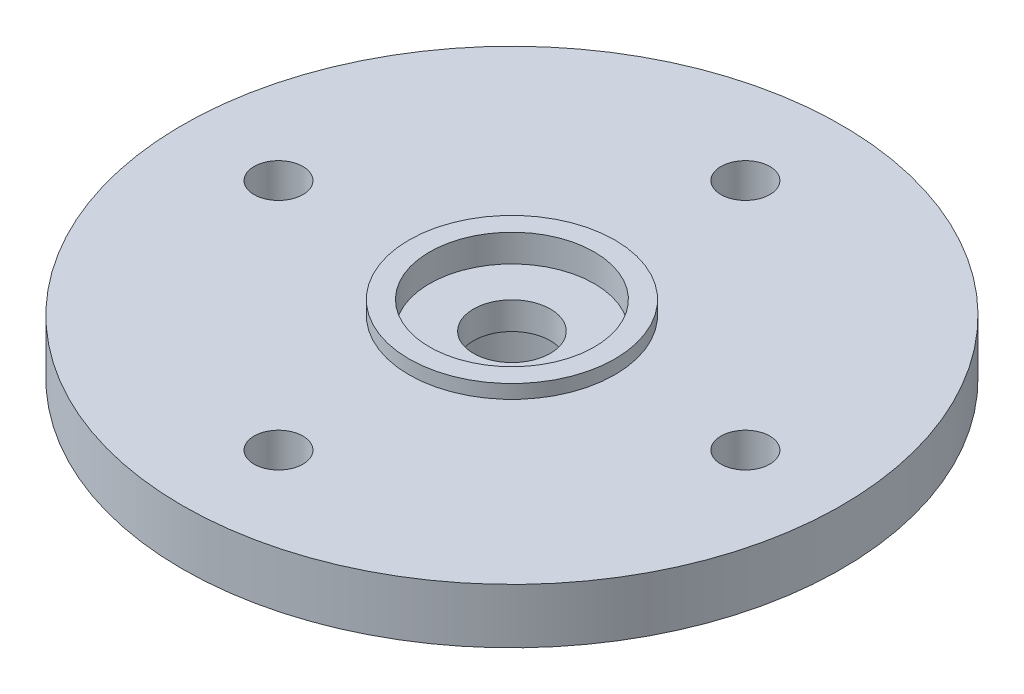
from build123d import *

# Parameters (mm, degrees)
SKETCH1_W                  = 12
SKETCH1_H                  = 2
SKETCH2_R                  = 4.5
BOSS_EXTRUDE1_DEPTH        = 2.5
SKETCH3_R                  = 3.75
BOSS_EXTRUDE2_DEPTH        = 0.5
M1_6_CLEARANCE_HOLE1_D     = 1.778
M1_6_CLEARANCE_HOLE1_DEPTH = 2.5


with BuildPart() as part:
    # Sketch1 → Revolve1 (revolve)
    with BuildSketch(Plane(origin=(0, 0, 0), x_dir=(-1, 0, 0), z_dir=(0, 0, -1))):
        with Locations((38.069, 69.05714)):
            Rectangle(SKETCH1_W, SKETCH1_H)
    revolve(axis=Axis((-44.069, 68.05714, 0), (0, 1, 0)))

    # Sketch2 → Boss-Extrude1 (add)
    with BuildSketch(Plane.XZ.offset(-68.05714)):
        with Locations((-44.069, 0)):
            Circle(SKETCH2_R)
    extrude(amount=BOSS_EXTRUDE1_DEPTH)

    # Sketch3 → Boss-Extrude2 (add)
    with BuildSketch(Plane(origin=(0, 70.05714, 0), x_dir=(-1, 0, 0), z_dir=(0, 1, 0))):
        with Locations((44.069, 0)):
            Circle(SKETCH3_R)
    extrude(amount=BOSS_EXTRUDE2_DEPTH)

    # Sketch4 → Cut-Revolve1 (revolve, cut)
    with BuildSketch(Plane.XY):
        Polygon((-41.069, 70.55714), (-44.069, 70.55714), (-44.069, 65.55714), (-41.069, 65.55714), (-41.069, 68.55714), (-42.669, 68.55714), (-42.669, 69.55714), (-41.069, 69.55714), align=None)
    revolve(axis=Axis((-44.069, 70.55714, 0), (0, -1, 0)), mode=Mode.SUBTRACT)

    # M1.6 Clearance Hole1
    with Locations(Plane(origin=(0, 68.05714, 0), x_dir=(-1, 0, 0), z_dir=(0, -1, 0))):
        with Locations((44.069, 8.5), (52.569, 0), (35.569, 0), (44.069, -8.5)):
            Hole(M1_6_CLEARANCE_HOLE1_D / 2, depth=M1_6_CLEARANCE_HOLE1_DEPTH)


solid = part.part
